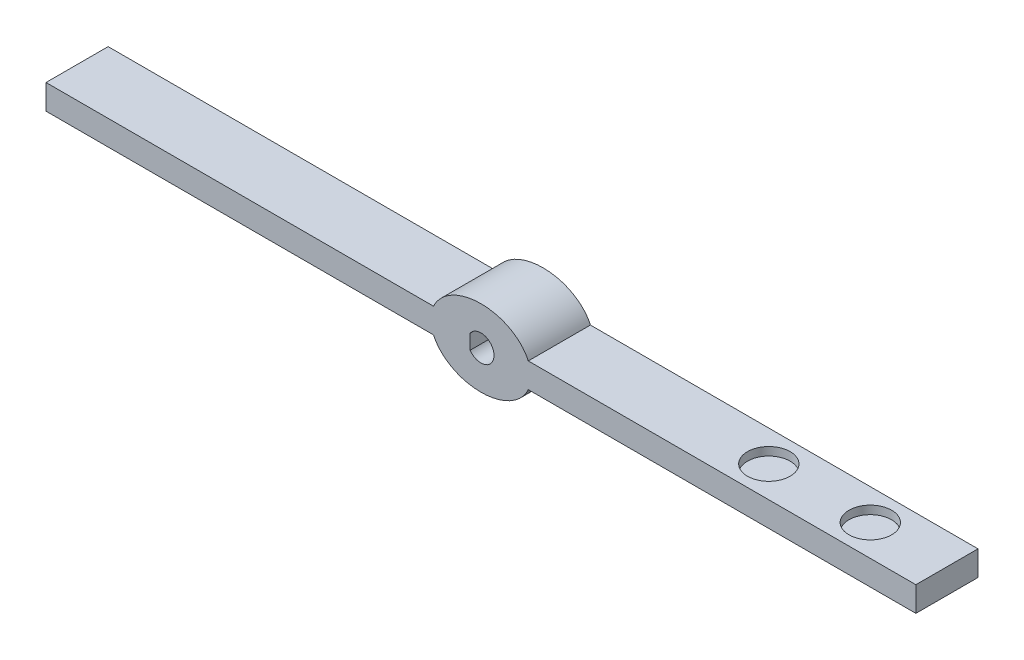
from build123d import *

# Parameters (mm, degrees)
SKETCH1_W           = 210
SKETCH1_H           = 6
BOSS_EXTRUDE1_DEPTH = 15
SKETCH2_RX          = 12.084795348
SKETCH2_RY          = 9.25941939
BOSS_EXTRUDE2_DEPTH = 15
SKETCH3_R           = 3.15
CUT_EXTRUDE1_DEPTH  = 15
BOSS_EXTRUDE3_DEPTH = 15
SKETCH5_R           = 5.15
CUT_EXTRUDE2_DEPTH  = 2
SKETCH6_R           = 5.15
CUT_EXTRUDE3_DEPTH  = 2


with BuildPart() as part:
    # Sketch1 → Boss-Extrude1 (new body)
    with BuildSketch(Plane.XY):
        with Locations((19.744707347, 18.183063512)):
            Rectangle(SKETCH1_W, SKETCH1_H)
    extrude(amount=BOSS_EXTRUDE1_DEPTH)

    # Sketch2 → Boss-Extrude2 (add)
    with BuildSketch(Plane.XY.offset(15)):
        with Locations((19.744707347, 18.183063512)):
            Ellipse(SKETCH2_RX, SKETCH2_RY)
    extrude(amount=-BOSS_EXTRUDE2_DEPTH)

    # Sketch3 → Cut-Extrude1 (cut)
    with BuildSketch(Plane.XY.offset(15)):
        with Locations((19.744707347, 18.183063512)):
            Circle(SKETCH3_R)
    extrude(amount=-CUT_EXTRUDE1_DEPTH, mode=Mode.SUBTRACT)

    # Sketch4 → Boss-Extrude3 (add)
    with BuildSketch(Plane.XY.offset(15)):
        with BuildLine():
            Line((17.144707347, 19.961405436), (17.144707347, 16.404721587))
            ThreePointArc((17.144707347, 16.404721587), (16.583900133, 18.183063512), (17.144707347, 19.961405436))
        make_face()
    extrude(amount=-BOSS_EXTRUDE3_DEPTH)

    # Sketch5 → Cut-Extrude2 (cut)
    with BuildSketch(Plane.XZ.offset(-15.183063512)):
        with Locations((-42.255292653, 7.5)):
            Circle(SKETCH5_R)
        with Locations((-66.755292653, 7.5)):
            Circle(SKETCH5_R)
    extrude(amount=-CUT_EXTRUDE2_DEPTH, mode=Mode.SUBTRACT)

    # Sketch6 → Cut-Extrude3 (cut)
    with BuildSketch(Plane(origin=(0, 21.183063512, 0), x_dir=(1, 0, 0), z_dir=(0, 1, 0))):
        with Locations((81.744707347, -7.5)):
            Circle(SKETCH6_R)
        with Locations((106.244707347, -7.5)):
            Circle(SKETCH6_R)
    extrude(amount=-CUT_EXTRUDE3_DEPTH, mode=Mode.SUBTRACT)


solid = part.part
